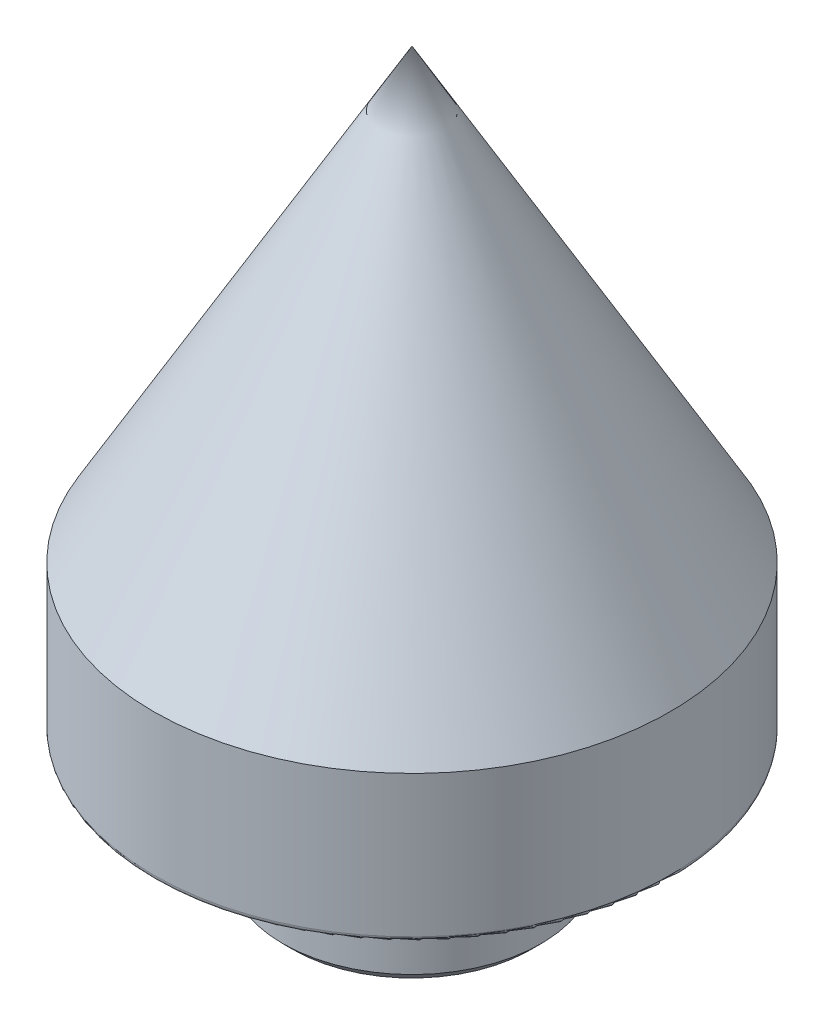
from build123d import *

# Parameters (mm, degrees)
SKETCH2_R                        = 0.762
CHAMFER1_SIZE                    = 0.508
FILLET1_R                        = 0.254
F_10_32_TAPPED_HOLE1_D           = 4.0386
F_10_32_TAPPED_HOLE1_DEPTH       = 10.3124
F_10_32_TAPPED_HOLE1_CSINK_D     = 4.826
F_10_32_TAPPED_HOLE1_CSINK_ANGLE = 90
F_10_32_TAPPED_HOLE1_TIP         = 1.213317848


with BuildPart() as part:
    # Sketch1 → Revolve1 (revolve)
    with BuildSketch(Plane.XY, mode=Mode.PRIVATE) as revolve1_sk:
        Polygon((12.7, 0), (6.35, 0), (6.35, -6.35), (0, -6.35), (0, 29.21), (12.7, 7.212954744), align=None)
    revolve(revolve1_sk.sketch.rotate(Axis((0, 35.289344262, 0), (0, -1, 0)), 90), axis=Axis((0, 35.289344262, 0), (0, -1, 0)))  # turned: the seam where the file's is

    # Sketch2 → Cut-Revolve1 (revolve, cut)
    with BuildSketch(Plane.XY, mode=Mode.PRIVATE) as cut_revolve1_sk:
        with Locations((6.858, -0.508)):
            Circle(SKETCH2_R)
    revolve(cut_revolve1_sk.sketch.rotate(Axis((0, 0, 0), (0, -1, 0)), 90), axis=Axis((0, 0, 0), (0, -1, 0)), mode=Mode.SUBTRACT)  # turned: the seam where the file's is

    # Chamfer1
    chamfer1_edges = [part.edges().sort_by_distance(p)[0] for p in [
        (0, -6.35, -6.35),
    ]]
    chamfer(chamfer1_edges, length=CHAMFER1_SIZE)

    # Fillet1
    fillet1_edges = [part.edges().sort_by_distance(p)[0] for p in [
        (0, 0, -12.7),
    ]]
    fillet(fillet1_edges, radius=FILLET1_R)

    # 10-32 Tapped Hole1
    with Locations(Plane.XZ.offset(6.35)):
        with Locations((0, 0)):
            CounterSinkHole(F_10_32_TAPPED_HOLE1_D / 2, F_10_32_TAPPED_HOLE1_CSINK_D / 2, depth=F_10_32_TAPPED_HOLE1_DEPTH, counter_sink_angle=F_10_32_TAPPED_HOLE1_CSINK_ANGLE)
            with Locations((0, 0, -(F_10_32_TAPPED_HOLE1_DEPTH + F_10_32_TAPPED_HOLE1_TIP / 2))):  # 118° drill point
                Cone(0, F_10_32_TAPPED_HOLE1_D / 2, F_10_32_TAPPED_HOLE1_TIP, mode=Mode.SUBTRACT)


solid = part.part
